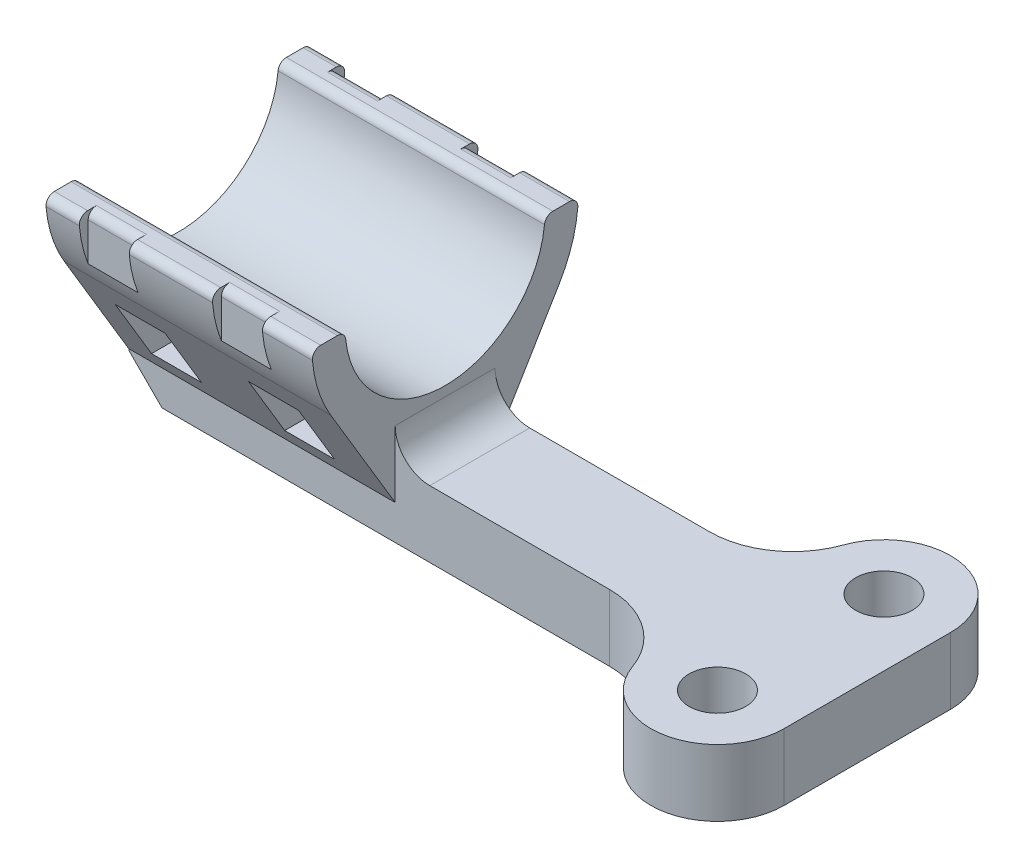
from build123d import *

# Parameters (mm, degrees)
SKETCH1_R               = 1.7
BOSS_EXTRUDE1_DEPTH     = 4
BOSS_EXTRUDE2_DEPTH     = 16
CHAMFER1_SIZE           = 2
FILLET1_R               = 2.08
SKETCH4_W               = 3
SKETCH4_H               = 2.145
CUT_EXTRUDE1_DEPTH      = 7
CUT_EXTRUDE1_DEPTH_BACK = 13
CHAMFER2_SIZE           = 1.705
CHAMFER2_SIZE2          = 1.750863319
CHAMFER2_PART_2_SIZE    = 1.705
CHAMFER2_PART_2_SIZE2   = 1.750863319
CUT_EXTRUDE2_DEPTH      = 3
CUT_EXTRUDE3_DEPTH      = 3


with BuildPart() as part:
    # Sketch1 → Boss-Extrude1 (new body)
    with BuildSketch(Plane(origin=(0, 0, 0), x_dir=(1, 0, 0), z_dir=(0, 1, 0))):
        with BuildLine():
            Line((0, 0), (12.869718626, 0))
            ThreePointArc((12.869718626, 0), (15.756469972, -0.917517095), (17.583763834, -3.333333333))
            ThreePointArc((17.583763834, -3.333333333), (22.031407915, -5.942394239), (25.355, -2))
            Line((25.355, -2), (25.355, 8))
            ThreePointArc((25.355, 8), (22.031407915, 11.942394239), (17.583763834, 9.333333333))
            ThreePointArc((17.583763834, 9.333333333), (15.756469972, 6.917517095), (12.869718626, 6))
            Line((12.869718626, 6), (0, 6))
            Line((0, 6), (0, 0))
        make_face()
        with Locations((21.355, -2)):
            Circle(SKETCH1_R, mode=Mode.SUBTRACT)
        with Locations((21.355, 8)):
            Circle(SKETCH1_R, mode=Mode.SUBTRACT)
    extrude(amount=BOSS_EXTRUDE1_DEPTH)

    # Sketch2 → Boss-Extrude2 (add)
    with BuildSketch(Plane.ZY):
        with BuildLine():
            Line((-6, 0), (0, 0))
            Line((0, 0), (0, 2.084))
            Line((0, 2.084), (3.867185515, 8.555128278))
            ThreePointArc((3.867185515, 8.555128278), (4.610527286, 10.193259862), (4.969057957, 11.956066667))
            ThreePointArc((4.969057957, 11.956066667), (4.839751016, 12.337663541), (4.470991835, 12.5))
            Line((4.470991835, 12.5), (3.466507481, 12.5))
            ThreePointArc((3.466507481, 12.5), (3.131355391, 12.371043228), (2.969083828, 12.050692308))
            ThreePointArc((2.969083828, 12.050692308), (-3, 6.659), (-8.969083828, 12.050692308))
            ThreePointArc((-8.969083828, 12.050692308), (-9.131355391, 12.371043228), (-9.466507481, 12.5))
            Line((-9.466507481, 12.5), (-10.470991835, 12.5))
            ThreePointArc((-10.470991835, 12.5), (-10.839751016, 12.337663541), (-10.969057957, 11.956066667))
            ThreePointArc((-10.969057957, 11.956066667), (-10.610527286, 10.193259862), (-9.867185515, 8.555128278))
            Line((-9.867185515, 8.555128278), (-6, 2.084))
            Line((-6, 2.084), (-6, 0))
        make_face()
    extrude(amount=BOSS_EXTRUDE2_DEPTH)

    # Chamfer1
    chamfer1_edges = [part.edges().sort_by_distance(p)[0] for p in [
        (-16, 0, -3),
    ]]
    chamfer(chamfer1_edges, length=CHAMFER1_SIZE)

    # Fillet1
    fillet1_edges = [part.edges().sort_by_distance(p)[0] for p in [
        (0, 4, -3),
    ]]
    fillet(fillet1_edges, radius=FILLET1_R)

    # Sketch4 → Cut-Extrude1 (cut, two sides)
    with BuildSketch(Plane.XY) as cut_extrude1_sk:
        with Locations((-12.5, 4.2165)):
            Rectangle(SKETCH4_W, SKETCH4_H)
        with Locations((-4.5, 4.2165)):
            Rectangle(SKETCH4_W, SKETCH4_H)
    extrude(amount=CUT_EXTRUDE1_DEPTH, mode=Mode.SUBTRACT)
    extrude(cut_extrude1_sk.sketch, amount=-CUT_EXTRUDE1_DEPTH_BACK, mode=Mode.SUBTRACT)

    # Chamfer2
    chamfer2_edges = [part.edges().sort_by_distance(p)[0] for p in [
        (-4.5, 5.289, -7.915327442),
        (-4.5, 5.289, 1.915327442),
    ]]
    chamfer2_side = [part.faces().sort_by_distance(p)[0] for p in [
        (-4.5, 5.289, -3),
    ]]
    chamfer(chamfer2_edges, length=CHAMFER2_SIZE, length2=CHAMFER2_SIZE2, reference=chamfer2_side[0])

    # Chamfer2 part 2
    chamfer2_part_2_edges = [part.edges().sort_by_distance(p)[0] for p in [
        (-12.5, 5.289, -7.915327442),
        (-12.5, 5.289, 1.915327442),
    ]]
    chamfer2_part_2_side = [part.faces().sort_by_distance(p)[0] for p in [
        (-12.5, 5.289, -3),
    ]]
    chamfer(chamfer2_part_2_edges, length=CHAMFER2_PART_2_SIZE, length2=CHAMFER2_PART_2_SIZE2, reference=chamfer2_part_2_side[0])

    # Sketch5 → Cut-Extrude2 (cut)
    with BuildSketch(Plane.ZY.offset(14)):
        with BuildLine():
            Line((4.439002016, 9.716), (4.439002016, 12))
            ThreePointArc((4.439002016, 12), (4.292555407, 12.353553391), (3.939002016, 12.5))
            Line((3.939002016, 12.5), (4.470991835, 12.5))
            ThreePointArc((4.470991835, 12.5), (4.839751016, 12.337663541), (4.969057957, 11.956066667))
            ThreePointArc((4.969057957, 11.956066667), (4.785021047, 10.816868818), (4.439002016, 9.716))
        make_face()
        with BuildLine():
            Line((-9.939002016, 12.5), (-10.470991835, 12.5))
            ThreePointArc((-10.470991835, 12.5), (-10.839751016, 12.337663541), (-10.969057957, 11.956066667))
            ThreePointArc((-10.969057957, 11.956066667), (-10.785021047, 10.816868818), (-10.439002016, 9.716))
            Line((-10.439002016, 9.716), (-10.439002016, 12))
            ThreePointArc((-10.439002016, 12), (-10.292555407, 12.353553391), (-9.939002016, 12.5))
        make_face()
    extrude(amount=-CUT_EXTRUDE2_DEPTH, mode=Mode.SUBTRACT)

    # Sketch6 → Cut-Extrude3 (cut)
    with BuildSketch(Plane.ZY.offset(6)):
        with BuildLine():
            Line((4.470991835, 12.5), (3.939002016, 12.5))
            ThreePointArc((3.939002016, 12.5), (4.292555407, 12.353553391), (4.439002016, 12))
            Line((4.439002016, 12), (4.439002016, 9.716))
            ThreePointArc((4.439002016, 9.716), (4.785021047, 10.816868818), (4.969057957, 11.956066667))
            ThreePointArc((4.969057957, 11.956066667), (4.839751016, 12.337663541), (4.470991835, 12.5))
        make_face()
        with BuildLine():
            Line((-9.939002016, 12.5), (-10.470991835, 12.5))
            ThreePointArc((-10.470991835, 12.5), (-10.839751016, 12.337663541), (-10.969057957, 11.956066667))
            ThreePointArc((-10.969057957, 11.956066667), (-10.785021047, 10.816868818), (-10.439002016, 9.716))
            Line((-10.439002016, 9.716), (-10.439002016, 12))
            ThreePointArc((-10.439002016, 12), (-10.292555407, 12.353553391), (-9.939002016, 12.5))
        make_face()
    extrude(amount=-CUT_EXTRUDE3_DEPTH, mode=Mode.SUBTRACT)


solid = part.part
